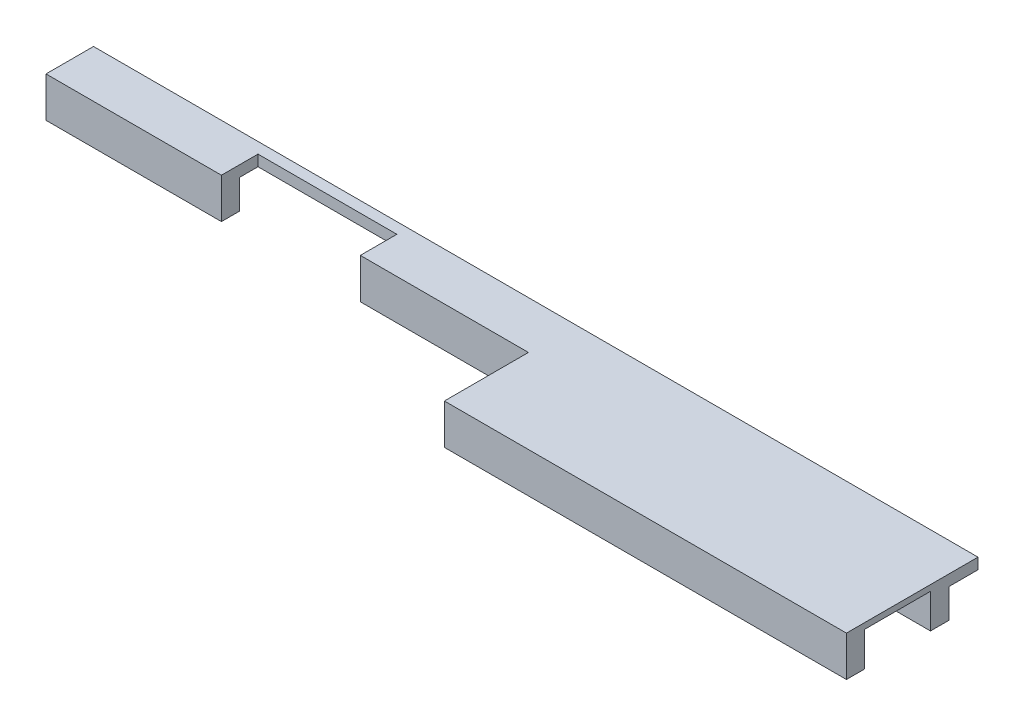
from build123d import *

# Parameters (mm, degrees)
SKETCH1_W               = 120
SKETCH1_H               = 137
BOSS_EXTRUDE1_DEPTH     = 3
SKETCH2_W               = 120
SKETCH2_H               = 5
BOSS_EXTRUDE2_DEPTH     = 8
SKETCH3_W               = 38
SKETCH3_H               = 10
CUT_EXTRUDE1_DEPTH      = 25
SKETCH4_W               = 120
SKETCH4_H               = 124
CUT_EXTRUDE2_DEPTH      = 92.412526494
CUT_EXTRUDE2_DEPTH_BACK = 92.412526494
BOSS_EXTRUDE3_DEPTH     = 7
BOSS_EXTRUDE4_DEPTH     = 120
SKETCH9_W               = 5
SKETCH9_H               = 23
CUT_EXTRUDE3_DEPTH      = 203.220795172
CUT_EXTRUDE3_DEPTH_BACK = 203.220795172
MOVE_FACE1_BY           = 5


with BuildPart() as part:
    # Sketch1 → Boss-Extrude1 (new body)
    with BuildSketch(Plane(origin=(0, 0, 0), x_dir=(1, 0, 0), z_dir=(0, 1, 0))):
        Rectangle(SKETCH1_W, SKETCH1_H)
    extrude(amount=BOSS_EXTRUDE1_DEPTH)

    # Sketch2 → Boss-Extrude2 (add)
    with BuildSketch(Plane(origin=(0, 3, 0), x_dir=(1, 0, 0), z_dir=(0, 1, 0))):
        with Locations((0, -66)):
            Rectangle(SKETCH2_W, SKETCH2_H)
    extrude(amount=BOSS_EXTRUDE2_DEPTH)

    # Sketch3 → Cut-Extrude1 (cut)
    with BuildSketch(Plane(origin=(0, 11, 0), x_dir=(1, 0, 0), z_dir=(0, 1, 0))):
        with Locations((0, -63.5)):
            Rectangle(SKETCH3_W, SKETCH3_H)
    extrude(amount=-CUT_EXTRUDE1_DEPTH, mode=Mode.SUBTRACT)

    # Sketch4 → Cut-Extrude2 (cut, two sides)
    with BuildSketch(Plane(origin=(0, 3, 0), x_dir=(1, 0, 0), z_dir=(0, 1, 0))) as cut_extrude2_sk:
        with Locations((0, 6.5)):
            Rectangle(SKETCH4_W, SKETCH4_H)
    extrude(amount=CUT_EXTRUDE2_DEPTH, mode=Mode.SUBTRACT)
    extrude(cut_extrude2_sk.sketch, amount=-CUT_EXTRUDE2_DEPTH_BACK, mode=Mode.SUBTRACT)

    # Sketch7 → Boss-Extrude3 (add)
    with BuildSketch(Plane.ZY.offset(60)):
        Polygon((63.5, 11), (63.5, 3), (55.5, 3), (55.5, 0), (68.5, 0), (68.5, 11), align=None)
    extrude(amount=BOSS_EXTRUDE3_DEPTH)

    # Sketch8 → Boss-Extrude4 (add)
    with BuildSketch(Plane(origin=(60, 0, 0), x_dir=(0, 0, -1), z_dir=(1, 0, 0))):
        Polygon((-55.5, 0), (-55.5, 3), (-63.5, 3), (-63.5, 11), (-68.5, 11), (-68.5, 1.6), (-86.5, 1.6), (-86.5, 11), (-91.5, 11), (-91.5, 0), align=None)
    extrude(amount=BOSS_EXTRUDE4_DEPTH)


with BuildPart() as body_2:
    # Mirror2: mirrored copy
    add(part.part.mirror(Plane(origin=(0, 0, 0), x_dir=(0, 0, 1), z_dir=(0, -1, 0))))

    # Sketch9 → Cut-Extrude3 (cut, two sides)
    with BuildSketch(Plane(origin=(0, -11, 0), x_dir=(-1, 0, 0), z_dir=(0, -1, 0))) as cut_extrude3_sk:
        with Locations((-62.5, -80)):
            Rectangle(SKETCH9_W, SKETCH9_H)
    extrude(amount=CUT_EXTRUDE3_DEPTH, mode=Mode.SUBTRACT)
    extrude(cut_extrude3_sk.sketch, amount=-CUT_EXTRUDE3_DEPTH_BACK, mode=Mode.SUBTRACT)

    # Move Face1: a face moved inward by 5.0
    extrude(body_2.faces().sort_by_distance((180, -1.1, 73.5))[0], amount=MOVE_FACE1_BY, dir=(-1, 0, 0), mode=Mode.SUBTRACT)


solid = body_2.part
